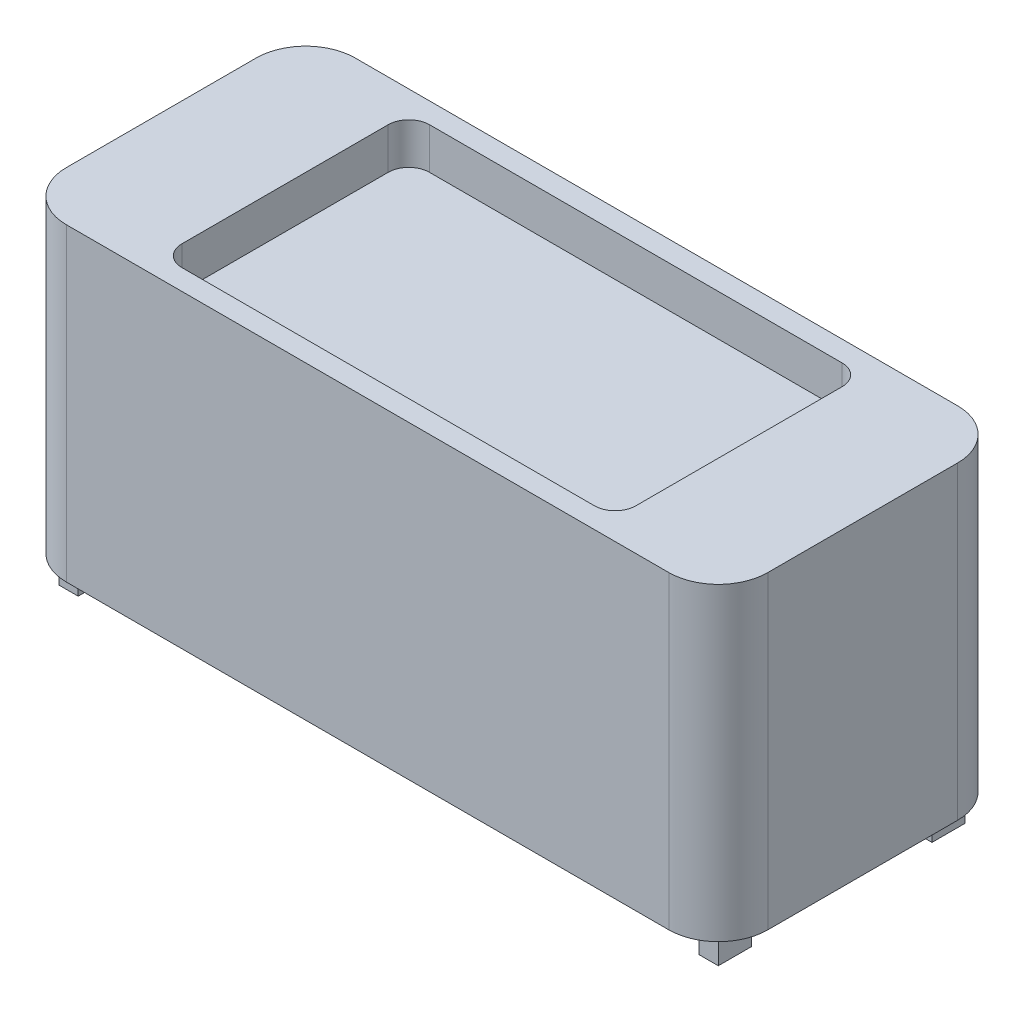
from build123d import *

# Parameters (mm, degrees)
BOSS_EXTRUDE1_DEPTH = 750
SKETCH1_3_W         = 1100
SKETCH1_3_H         = 600
CUT_EXTRUDE1_DEPTH  = 100
FILLET1_R           = 50.000000076
SKETCH2_W           = 47
SKETCH2_H           = 80.5
BOSS_EXTRUDE2_DEPTH = 66.215


with BuildPart() as part:
    # Sketch1 → Boss-Extrude1 (new body)
    with BuildSketch(Plane(origin=(0, 0, 0), x_dir=(1, 0, 0), z_dir=(0, 1, 0))):
        with BuildLine():
            Line((730, 350), (-730, 350))
            ThreePointArc((-730, 350), (-814.852813742, 314.852813742), (-850, 230))
            Line((-850, 230), (-850, -230))
            ThreePointArc((-850, -230), (-814.852813742, -314.852813742), (-730, -350))
            Line((-730, -350), (730, -350))
            ThreePointArc((730, -350), (814.852813742, -314.852813742), (850, -230))
            Line((850, -230), (850, 230))
            ThreePointArc((850, 230), (814.852813742, 314.852813742), (730, 350))
        make_face()
    extrude(amount=-BOSS_EXTRUDE1_DEPTH)

    # Sketch1_3 → Cut-Extrude1 (cut)
    with BuildSketch(Plane(origin=(0, 0, 0), x_dir=(1, 0, 0), z_dir=(0, 1, 0))):
        Rectangle(SKETCH1_3_W, SKETCH1_3_H)
    extrude(amount=-CUT_EXTRUDE1_DEPTH, mode=Mode.SUBTRACT)

    # Fillet1
    fillet1_edges = [part.edges().sort_by_distance(p)[0] for p in [
        (550, -50, 300),
        (-550, -50, 300),
        (550, -50, -300),
        (-550, -50, -300),
    ]]
    fillet(fillet1_edges, radius=FILLET1_R)

    # Sketch2 → Boss-Extrude2 (add)
    with BuildSketch(Plane.XZ.offset(750)):
        with Locations((-775.7, 258.95)):
            Rectangle(SKETCH2_W, SKETCH2_H)
        with Locations((775.7, 258.95)):
            Rectangle(SKETCH2_W, SKETCH2_H)
        with Locations((775.7, -258.95)):
            Rectangle(SKETCH2_W, SKETCH2_H)
        with Locations((-775.7, -258.95)):
            Rectangle(SKETCH2_W, SKETCH2_H)
    extrude(amount=BOSS_EXTRUDE2_DEPTH)


solid = part.part
